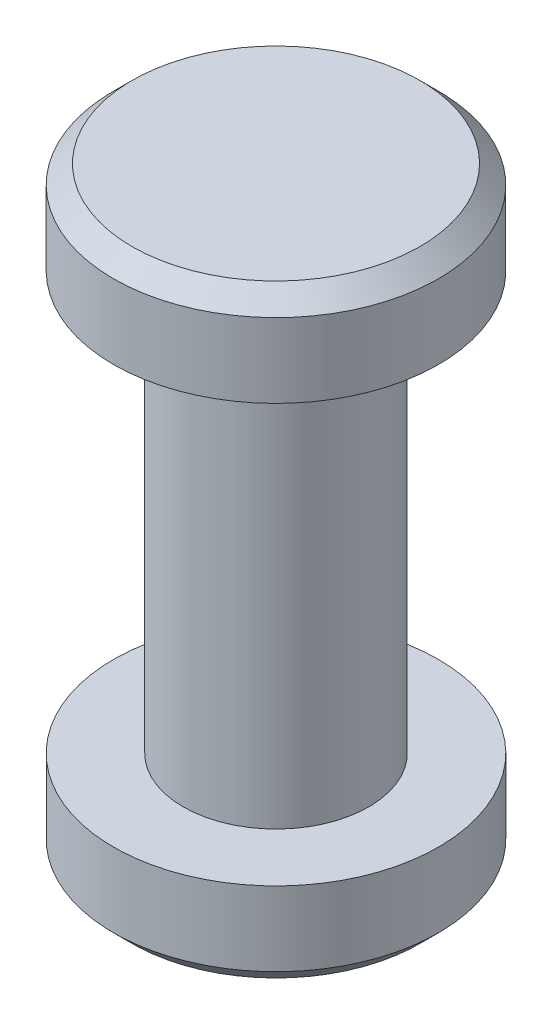
from build123d import *

# Parameters (mm, degrees)
SKETCH1_R           = 1
BOSS_EXTRUDE1_DEPTH = 4.5
SKETCH2_R           = 1.75
BOSS_EXTRUDE2_DEPTH = 1
CHAMFER1_SIZE       = 0.2
SKETCH3_R           = 1.75
BOSS_EXTRUDE3_DEPTH = 1
CHAMFER2_SIZE       = 0.2


with BuildPart() as part:
    # Sketch1 → Boss-Extrude1 (new body)
    with BuildSketch(Plane(origin=(0, 0, 0), x_dir=(1, 0, 0), z_dir=(0, 1, 0))):
        Circle(SKETCH1_R)
    extrude(amount=BOSS_EXTRUDE1_DEPTH)

    # Sketch2 → Boss-Extrude2 (add)
    with BuildSketch(Plane(origin=(0, 4.5, 0), x_dir=(1, 0, 0), z_dir=(0, 1, 0))):
        Circle(SKETCH2_R)
    extrude(amount=BOSS_EXTRUDE2_DEPTH)

    # Chamfer1
    chamfer1_edges = [part.edges().sort_by_distance(p)[0] for p in [
        (-1.75, 5.5, 0),
    ]]
    chamfer(chamfer1_edges, length=CHAMFER1_SIZE)

    # Sketch3 → Boss-Extrude3 (add)
    with BuildSketch(Plane.XZ):
        Circle(SKETCH3_R)
    extrude(amount=BOSS_EXTRUDE3_DEPTH)

    # Chamfer2
    chamfer2_edges = [part.edges().sort_by_distance(p)[0] for p in [
        (-1.75, -1, 0),
    ]]
    chamfer(chamfer2_edges, length=CHAMFER2_SIZE)


solid = part.part
